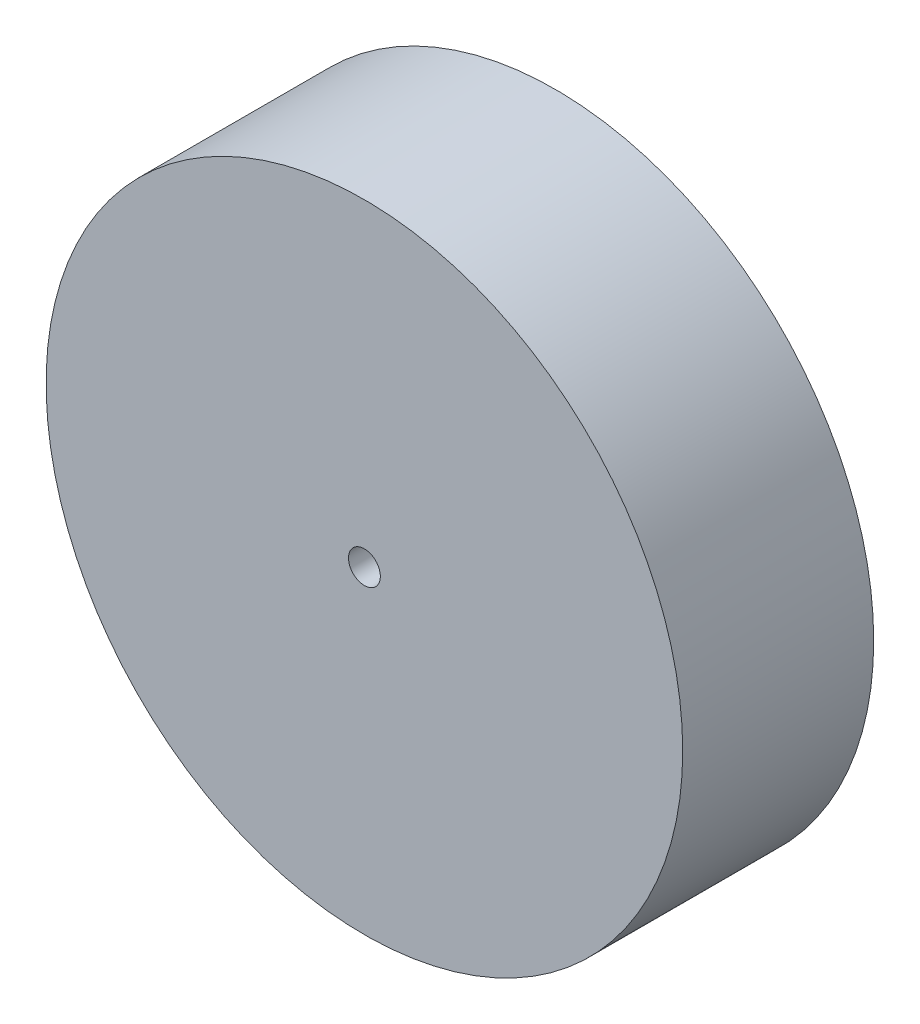
from build123d import *

# Parameters (mm, degrees)
SKETCH1_R           = 50
BOSS_EXTRUDE1_DEPTH = 30
SKETCH2_R           = 2.5
CUT_EXTRUDE1_DEPTH  = 31
SHELL1_T            = -10


with BuildPart() as part:
    # Sketch1 → Boss-Extrude1 (new body)
    with BuildSketch(Plane.XY):
        Circle(SKETCH1_R)
    extrude(amount=BOSS_EXTRUDE1_DEPTH)

    # Sketch2 → Cut-Extrude1 (cut, through all)
    with BuildSketch(Plane(origin=(0, 0, 0), x_dir=(-1, 0, 0), z_dir=(0, 0, -1))):
        Circle(SKETCH2_R)
    extrude(amount=-CUT_EXTRUDE1_DEPTH, mode=Mode.SUBTRACT)

    # Shell1
    shell1_openings = [part.faces().sort_by_distance(p)[0] for p in [
        (-2.5, 0, 0),
    ]]
    offset(amount=SHELL1_T, openings=shell1_openings, kind=Kind.INTERSECTION)


solid = part.part
